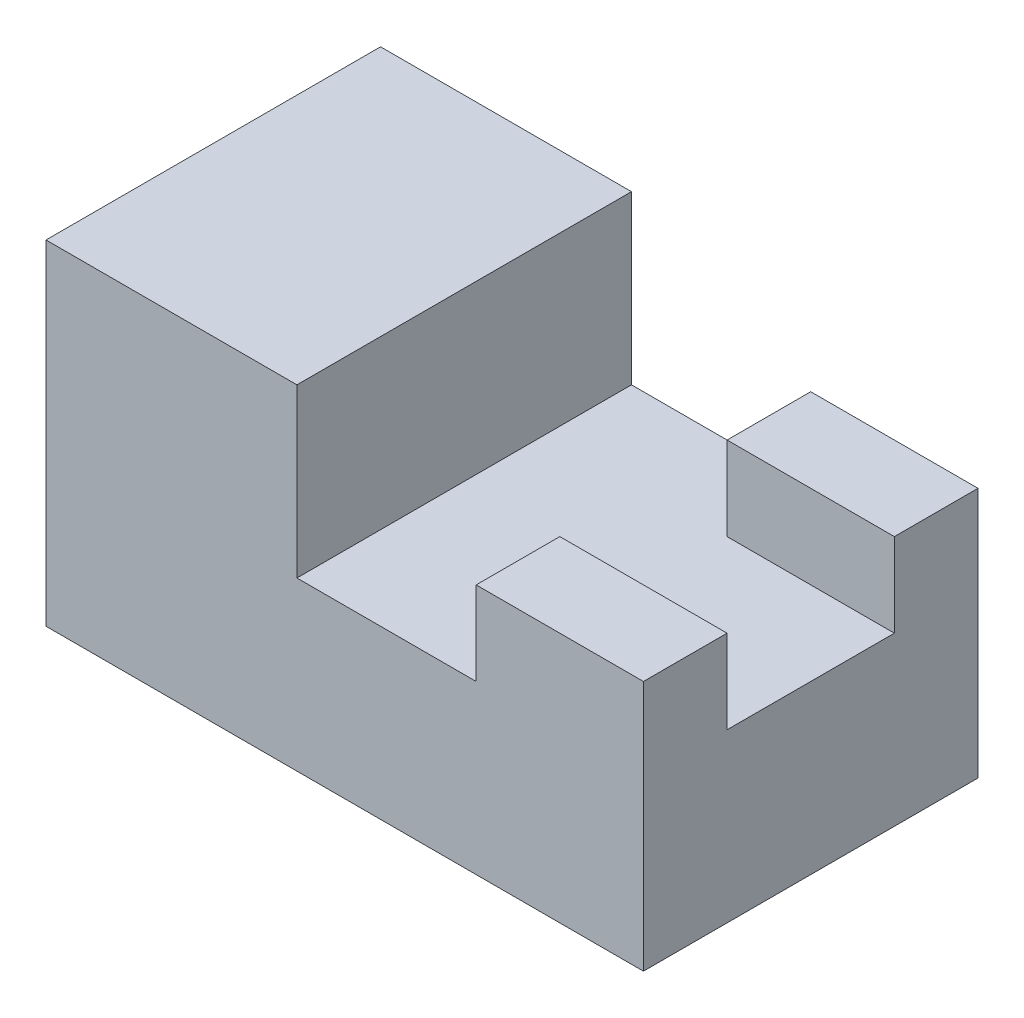
from build123d import *

# Parameters (mm, degrees)
BOSS_EXTRUDE1_DEPTH = 14
SKETCH1_3_W         = 21
SKETCH1_3_H         = 28
BOSS_EXTRUDE2_DEPTH = 28
SKETCH1_4_W         = 14
SKETCH1_4_H         = 7
BOSS_EXTRUDE3_DEPTH = 21


with BuildPart() as part:
    # Sketch1 → Boss-Extrude1 (new body)
    with BuildSketch(Plane(origin=(0, 0, 0), x_dir=(1, 0, 0), z_dir=(0, 1, 0))):
        Polygon((11, 14), (-4, 14), (-4, -14), (11, -14), (11, -7), (25, -7), (25, 7), (11, 7), align=None)
    extrude(amount=BOSS_EXTRUDE1_DEPTH)

    # Sketch1_3 → Boss-Extrude2 (add)
    with BuildSketch(Plane(origin=(0, 0, 0), x_dir=(1, 0, 0), z_dir=(0, 1, 0))):
        with Locations((-14.5, 0)):
            Rectangle(SKETCH1_3_W, SKETCH1_3_H)
    extrude(amount=BOSS_EXTRUDE2_DEPTH)

    # Sketch1_4 → Boss-Extrude3 (add)
    with BuildSketch(Plane(origin=(0, 0, 0), x_dir=(1, 0, 0), z_dir=(0, 1, 0))):
        with Locations((18, 10.5)):
            Rectangle(SKETCH1_4_W, SKETCH1_4_H)
        with Locations((18, -10.5)):
            Rectangle(SKETCH1_4_W, SKETCH1_4_H)
    extrude(amount=BOSS_EXTRUDE3_DEPTH)


solid = part.part
